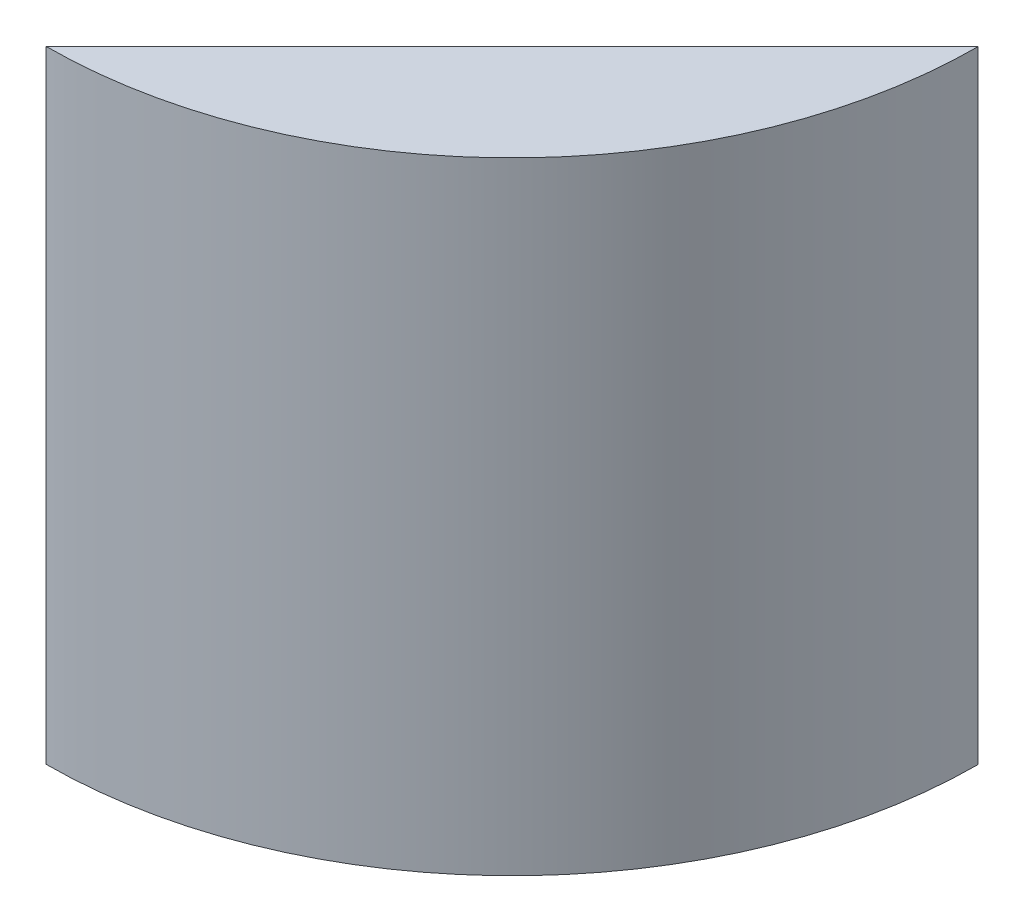
from build123d import *

# Parameters (mm, degrees)
SKETCH1_R           = 85.725
BOSS_EXTRUDE1_DEPTH = 114.3
CUT_EXTRUDE1_DEPTH  = 152.4
SKETCH4_R           = 2.778125
CUT_EXTRUDE2_DEPTH  = 12.7
SKETCH5_R           = 6.985
CUT_EXTRUDE3_DEPTH  = 6.35


with BuildPart() as part:
    # Sketch1 → Boss-Extrude1 (new body)
    with BuildSketch(Plane(origin=(0, 0, 0), x_dir=(1, 0, 0), z_dir=(0, 1, 0))):
        Circle(SKETCH1_R)
    extrude(amount=BOSS_EXTRUDE1_DEPTH)

    # Sketch2 → Cut-Extrude1 (cut)
    with BuildSketch(Plane(origin=(0, 114.3, 0), x_dir=(1, 0, 0), z_dir=(0, 1, 0))):
        Polygon((85.724933621, -0.10668), (0, -85.725), (-45.627504124, -96.719379999), (-137.428949547, 46.173941299), (19.12530113, 101.910533163), (109.833872203, 30.600481808), align=None)
    extrude(amount=-CUT_EXTRUDE1_DEPTH, mode=Mode.SUBTRACT)

    # Sketch4 → Cut-Extrude2 (cut)
    with BuildSketch(Plane(origin=(42.862466811, 0, 42.91584), x_dir=(-0.707546622, 0, 0.706666667), z_dir=(-0.706666667, 0, -0.707546622))):
        with Locations((40.618496709, 93.472)):
            Circle(SKETCH4_R)
        with Locations((-4.847503262, 93.472)):
            Circle(SKETCH4_R)
        with Locations((-4.847503262, 25.4)):
            Circle(SKETCH4_R)
        with Locations((40.618496632, 25.4)):
            Circle(SKETCH4_R)
    extrude(amount=-CUT_EXTRUDE2_DEPTH, mode=Mode.SUBTRACT)

    # Sketch5 → Cut-Extrude3 (cut)
    with BuildSketch(Plane(origin=(0, 0, 0), x_dir=(-1, 0, 0), z_dir=(0, -1, 0))):
        with Locations((-51.837133477, -51.901682099)):
            Circle(SKETCH5_R)
    extrude(amount=-CUT_EXTRUDE3_DEPTH, mode=Mode.SUBTRACT)


solid = part.part
